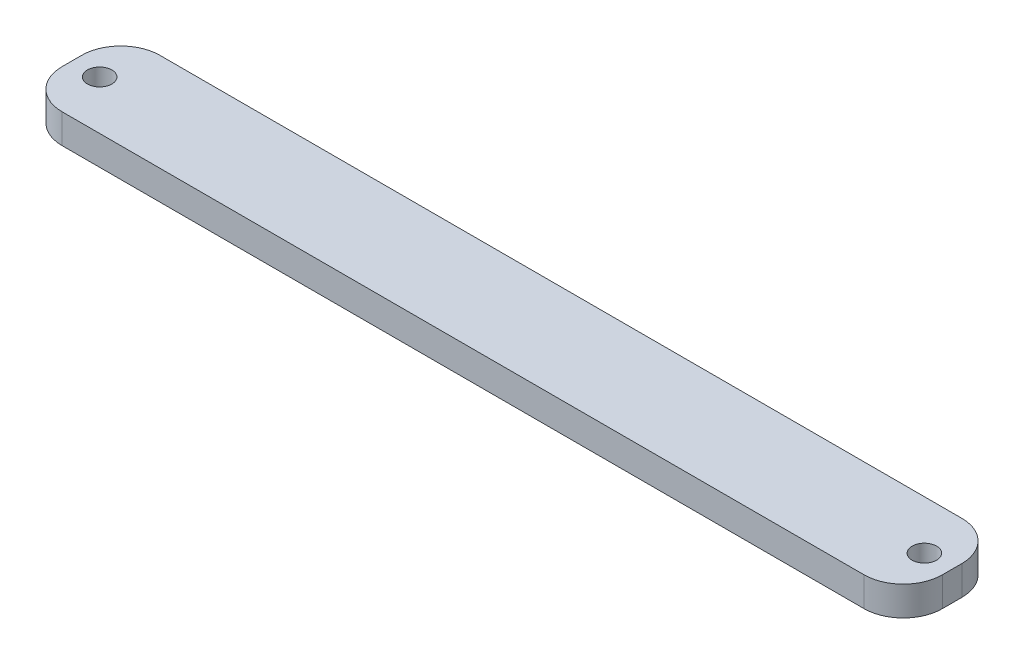
from build123d import *

# Parameters (mm, degrees)
SKETCH1_W           = 114.3
SKETCH1_H           = 12.7
EXTRUDE_THIN1_DEPTH = 3.81
FILLET1_R           = 5.08
SKETCH3_R           = 1.5875
CUT_EXTRUDE1_DEPTH  = 3.81


with BuildPart() as part:
    # Sketch1 → Extrude-Thin1 (new body)
    with BuildSketch(Plane(origin=(0, 0, 0), x_dir=(1, 0, 0), z_dir=(0, 1, 0))):
        with Locations((0, -6.35)):
            Rectangle(SKETCH1_W, SKETCH1_H)
    extrude(amount=EXTRUDE_THIN1_DEPTH)

    # Fillet1
    fillet1_edges = [part.edges().sort_by_distance(p)[0] for p in [
        (-57.15, 1.905, 12.7),
        (-57.15, 1.905, 0),
        (57.15, 1.905, 0),
        (57.15, 1.905, 12.7),
    ]]
    fillet(fillet1_edges, radius=FILLET1_R)

    # Sketch3 → Cut-Extrude1 (cut)
    with BuildSketch(Plane(origin=(0, 3.81, 0), x_dir=(1, 0, 0), z_dir=(0, 1, 0))):
        with Locations((53.54685275, -6.35)):
            Circle(SKETCH3_R)
    cut_extrude1 = extrude(amount=-CUT_EXTRUDE1_DEPTH, mode=Mode.SUBTRACT)

    # Mirror1: Cut-Extrude1 across plane
    add(cut_extrude1.mirror(Plane(origin=(0, 0, 0), x_dir=(0, 0, 1), z_dir=(1, 0, 0))), mode=Mode.SUBTRACT)


solid = part.part
